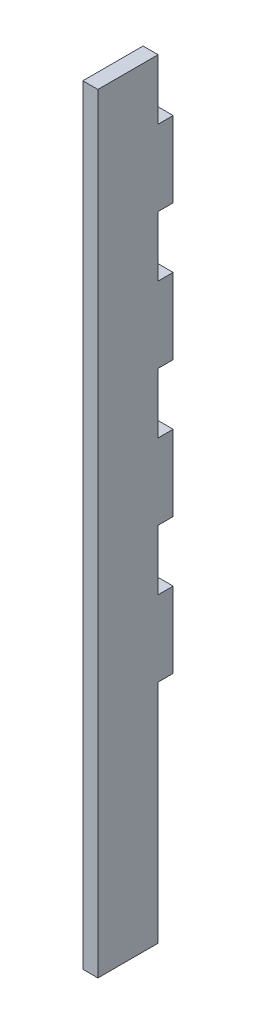
from build123d import *

# Parameters (mm, degrees)
BOSS_EXTRUDE1_DEPTH = 3.175


with BuildPart() as part:
    # Sketch1 → Boss-Extrude1 (new body)
    with BuildSketch(Plane(origin=(0, 0, 0), x_dir=(0, 0, -1), z_dir=(1, 0, 0))):
        Polygon((-7.9375, 0), (-7.9375, -162.306), (4.7625, -162.306), (4.7625, -155.956), (4.7625, -143.256), (4.7625, -127.3048), (4.7625, -114.6048), (7.9375, -114.6048), (7.9375, -98.6536), (4.7625, -98.6536), (4.7625, -85.9536), (7.9375, -85.9536), (7.9375, -70.0024), (4.7625, -70.0024), (4.7625, -57.3024), (7.9375, -57.3024), (7.9375, -41.3512), (4.7625, -41.3512), (4.7625, -28.6512), (7.9375, -28.6512), (7.9375, -12.7), (4.7625, -12.7), (4.7625, 0), align=None)
    extrude(amount=BOSS_EXTRUDE1_DEPTH)


solid = part.part
